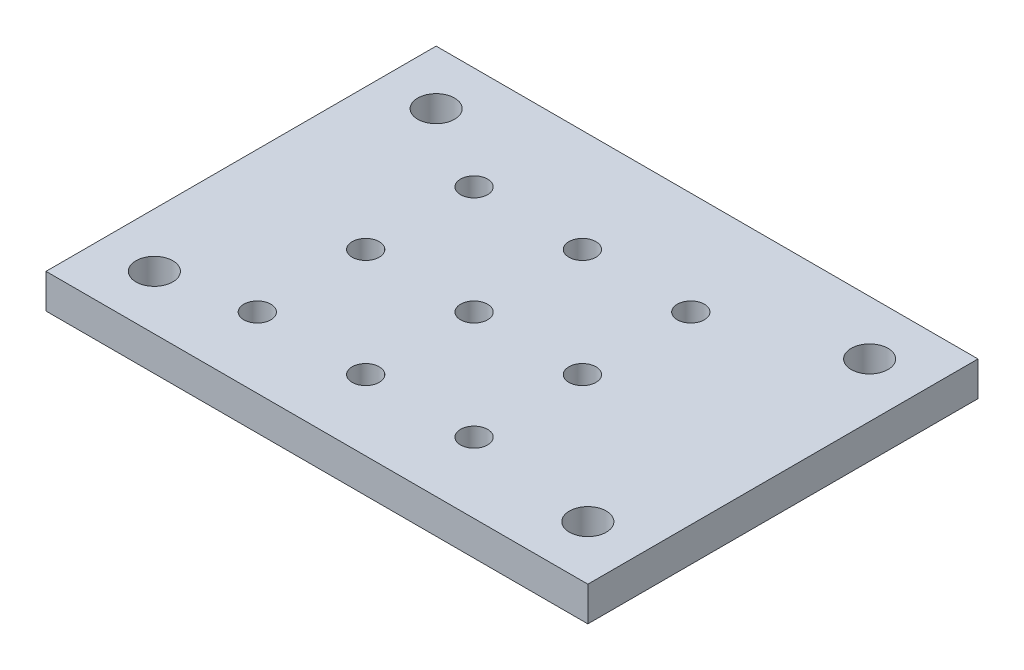
from build123d import *

# Parameters (mm, degrees)
SKETCH1_W           = 50
SKETCH1_H           = 36
SKETCH1_R           = 1.25
SKETCH1_R_2         = 1.7
BOSS_EXTRUDE1_DEPTH = 3.175


with BuildPart() as part:
    # Sketch1 → Boss-Extrude1 (new body)
    with BuildSketch(Plane(origin=(0, 0, 0), x_dir=(1, 0, 0), z_dir=(0, 1, 0))):
        with Locations((25, 18)):
            Rectangle(SKETCH1_W, SKETCH1_H)
        with Locations((13, 6.5)):
            Circle(SKETCH1_R, mode=Mode.SUBTRACT)
        with Locations((5, 5)):
            Circle(SKETCH1_R_2, mode=Mode.SUBTRACT)
        with Locations((5, 31)):
            Circle(SKETCH1_R_2, mode=Mode.SUBTRACT)
        with Locations((45, 31)):
            Circle(SKETCH1_R_2, mode=Mode.SUBTRACT)
        with Locations((45, 5)):
            Circle(SKETCH1_R_2, mode=Mode.SUBTRACT)
        with Locations((23, 6.5)):
            Circle(SKETCH1_R, mode=Mode.SUBTRACT)
        with Locations((33, 6.5)):
            Circle(SKETCH1_R, mode=Mode.SUBTRACT)
        with Locations((23, 16.5)):
            Circle(SKETCH1_R, mode=Mode.SUBTRACT)
        with Locations((33, 16.5)):
            Circle(SKETCH1_R, mode=Mode.SUBTRACT)
        with Locations((23, 26.5)):
            Circle(SKETCH1_R, mode=Mode.SUBTRACT)
        with Locations((33, 26.5)):
            Circle(SKETCH1_R, mode=Mode.SUBTRACT)
        with Locations((13, 16.5)):
            Circle(SKETCH1_R, mode=Mode.SUBTRACT)
        with Locations((13, 26.5)):
            Circle(SKETCH1_R, mode=Mode.SUBTRACT)
    extrude(amount=BOSS_EXTRUDE1_DEPTH)


solid = part.part
